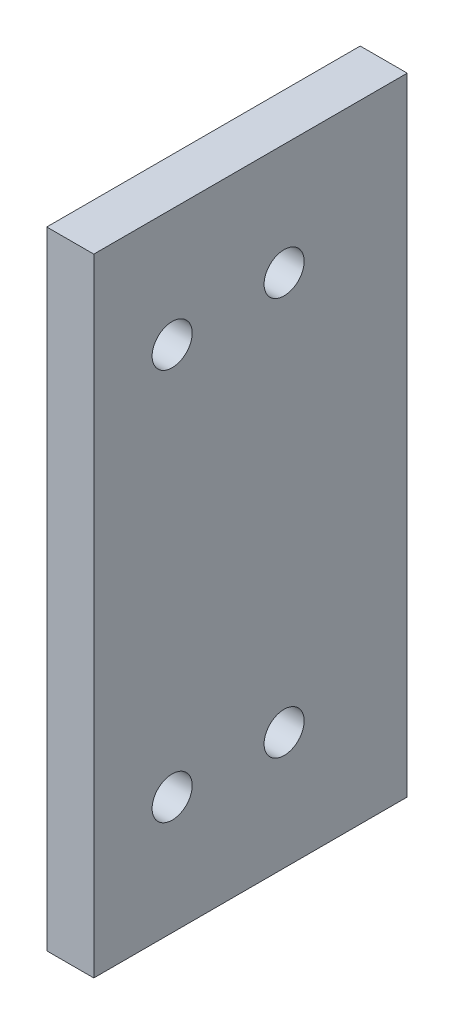
from build123d import *

# Parameters (mm, degrees)
SKETCH1_W           = 80
SKETCH1_H           = 40
BOSS_EXTRUDE2_DEPTH = 6
CUT_EXTRUDE3_REACH  = 47.122
SKETCH1_3_R         = 2.555


with BuildPart() as part:
    # Sketch1 → Boss-Extrude2 (new body)
    with BuildSketch(Plane.YZ):
        Rectangle(SKETCH1_W, SKETCH1_H)
    extrude(amount=BOSS_EXTRUDE2_DEPTH)

    # Sketch1_3 → Cut-Extrude3 (cut, up to next)
    with BuildSketch(Plane.YZ, mode=Mode.PRIVATE) as cut_extrude3_sk1:
        with Locations((-25, -4.29)):
            Circle(SKETCH1_3_R)
    cut_extrude3_tool1 = extrude(cut_extrude3_sk1.sketch, amount=CUT_EXTRUDE3_REACH, mode=Mode.PRIVATE) & part.part
    # Sketch1_3 → Cut-Extrude3 (cut, up to next)
    with BuildSketch(Plane.YZ, mode=Mode.PRIVATE) as cut_extrude3_sk2:
        with Locations((25.8, -4.29)):
            Circle(SKETCH1_3_R)
    cut_extrude3_tool2 = extrude(cut_extrude3_sk2.sketch, amount=CUT_EXTRUDE3_REACH, mode=Mode.PRIVATE) & part.part
    # Sketch1_3 → Cut-Extrude3 (cut, up to next)
    with BuildSketch(Plane.YZ, mode=Mode.PRIVATE) as cut_extrude3_sk3:
        with Locations((-25, 10)):
            Circle(SKETCH1_3_R)
    cut_extrude3_tool3 = extrude(cut_extrude3_sk3.sketch, amount=CUT_EXTRUDE3_REACH, mode=Mode.PRIVATE) & part.part
    # Sketch1_3 → Cut-Extrude3 (cut, up to next)
    with BuildSketch(Plane.YZ, mode=Mode.PRIVATE) as cut_extrude3_sk4:
        with Locations((25, 10)):
            Circle(SKETCH1_3_R)
    cut_extrude3_tool4 = extrude(cut_extrude3_sk4.sketch, amount=CUT_EXTRUDE3_REACH, mode=Mode.PRIVATE) & part.part
    add(cut_extrude3_tool1.solids().sort_by_distance((0, -25, -4.29))[0], mode=Mode.SUBTRACT)
    add(cut_extrude3_tool2.solids().sort_by_distance((0, 25.8, -4.29))[0], mode=Mode.SUBTRACT)
    add(cut_extrude3_tool3.solids().sort_by_distance((0, -25, 10))[0], mode=Mode.SUBTRACT)
    add(cut_extrude3_tool4.solids().sort_by_distance((0, 25, 10))[0], mode=Mode.SUBTRACT)


solid = part.part
